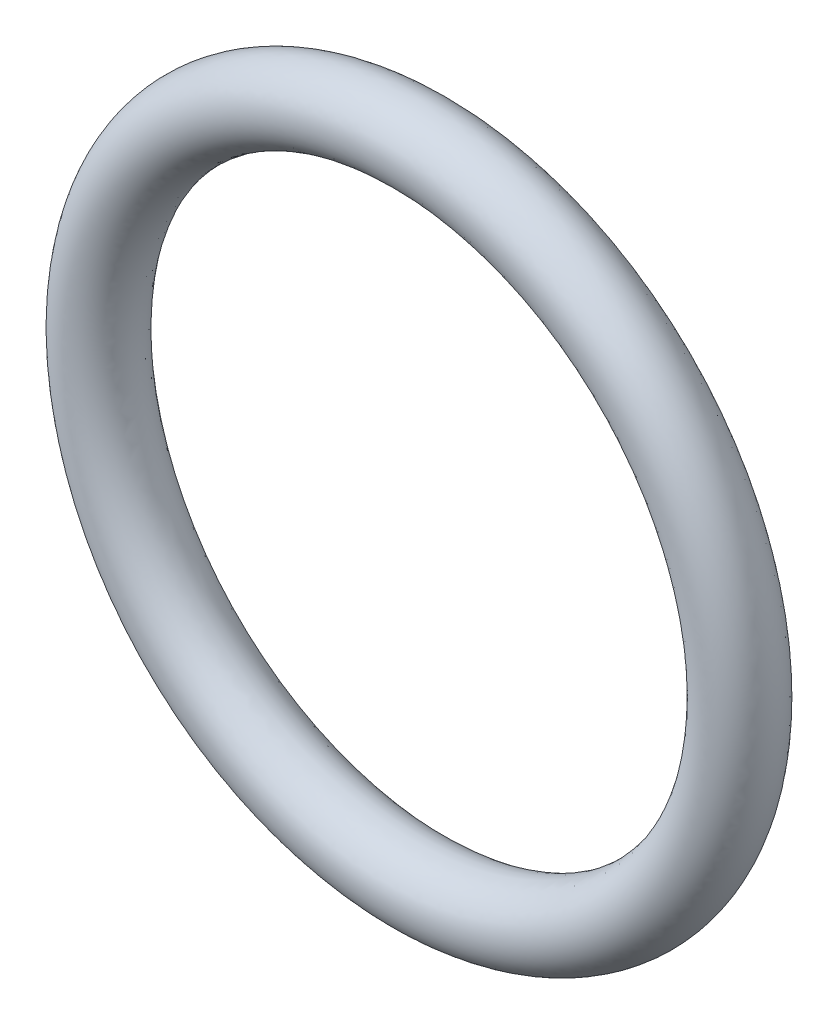
from build123d import *

# Parameters (mm, degrees)
ESQUISSE1_RX = 2.66
ESQUISSE1_RY = 2.66


with BuildPart() as part:
    # Esquisse1 → Base-Révolution (revolve)
    with BuildSketch(Plane(origin=(0, 0, 0), x_dir=(0, 0, -1), z_dir=(1, 0, 0))):
        with Locations((2.66, 22.98)):
            Ellipse(ESQUISSE1_RX, ESQUISSE1_RY)
    revolve(axis=Axis((0, 0, 0), (0, 0, -1)))


solid = part.part
